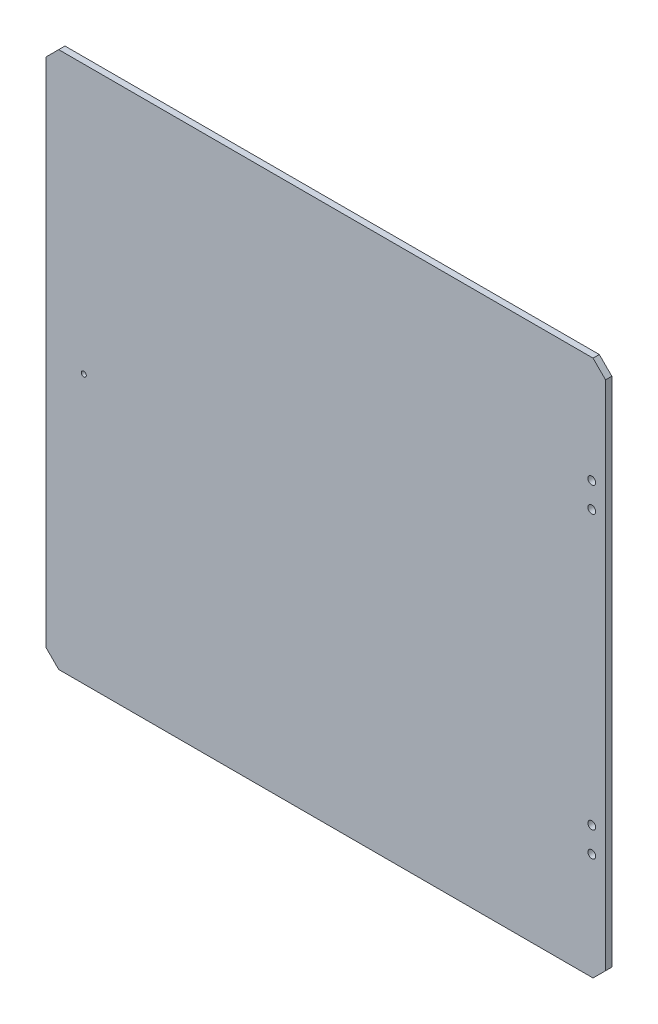
from build123d import *

# Parameters (mm, degrees)
SCHIZZO1_R                   = 3.1
SCHIZZO1_R_2                 = 2
ESTRUSIONE_ESTRUSIONE1_DEPTH = 5


with BuildPart() as part:
    # Schizzo1 → Estrusione-Estrusione1 (new body)
    with BuildSketch(Plane.XY):
        Polygon((-223, 204), (-213, 214), (213, 214), (223, 204), (223, -204), (213, -214), (-213, -214), (-223, -204), align=None)
        with Locations((212, 129)):
            Circle(SCHIZZO1_R, mode=Mode.SUBTRACT)
        with Locations((212, 109)):
            Circle(SCHIZZO1_R, mode=Mode.SUBTRACT)
        with Locations((212, -109)):
            Circle(SCHIZZO1_R, mode=Mode.SUBTRACT)
        with Locations((212, -129)):
            Circle(SCHIZZO1_R, mode=Mode.SUBTRACT)
        with Locations((-193, 0)):
            Circle(SCHIZZO1_R_2, mode=Mode.SUBTRACT)
    extrude(amount=ESTRUSIONE_ESTRUSIONE1_DEPTH)


solid = part.part
